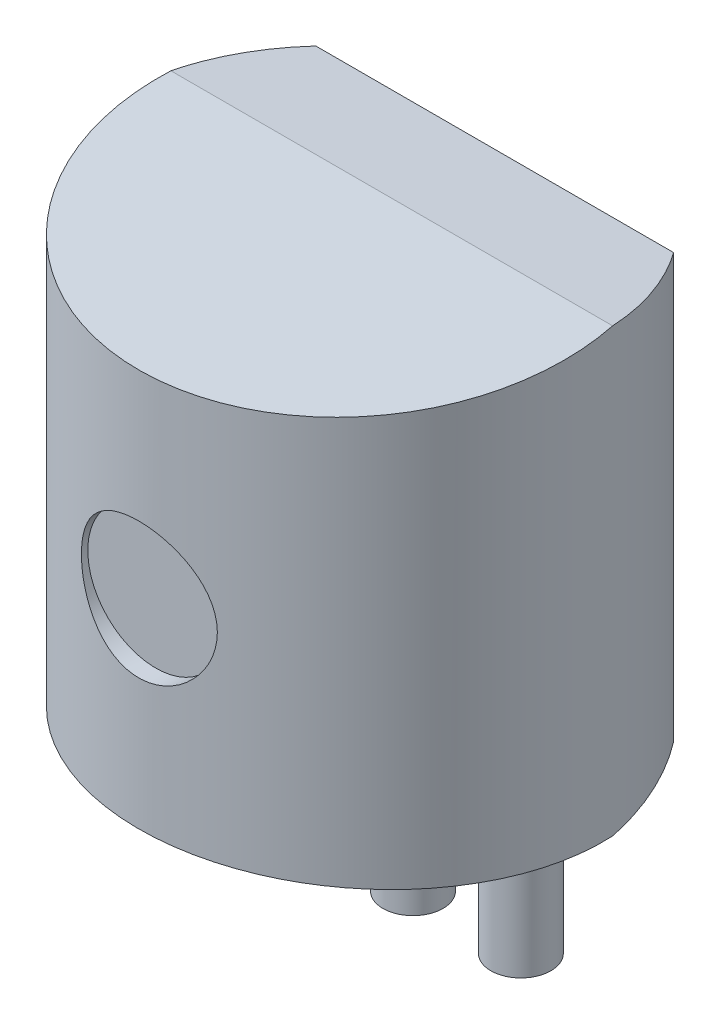
from build123d import *

# Parameters (mm, degrees)
BOSS_EXTRUDE1_DEPTH        = 2.6
SKETCH5_W                  = 11.826356456
SKETCH5_H                  = 5.621169426
CUT_EXTRUDE2_DEPTH         = 1.105635064
SKETCH6_W                  = 11.690711404
SKETCH6_H                  = 7.254613366
CUT_EXTRUDE3_DEPTH         = 5.2
BOSS_EXTRUDE2_START        = -0.052804
SKETCH7_R                  = 0.353553391
BOSS_EXTRUDE2_DEPTH        = 12.752804
SKETCH8_R                  = 0.8
CUT_EXTRUDE4_DEPTH         = 0.2
CROQUIS1_W                 = 6.923561314
CROQUIS1_H                 = 11.497610845
CORTAR_EXTRUIR1_DEPTH      = 5
CORTAR_EXTRUIR1_DEPTH_BACK = 5


with BuildPart() as part:
    # Sketch2 → Boss-Extrude1 (new body, symmetric)
    with BuildSketch(Plane(origin=(0, 0, 0), x_dir=(1, 0, 0), z_dir=(0, 1, 0))):
        with BuildLine():
            Line((-2.105447518, 1.212026432), (2.105447518, 1.212026432))
            ThreePointArc((2.105447518, 1.212026432), (0, -2.977973568), (-2.105447518, 1.212026432))
        make_face()
    extrude(amount=BOSS_EXTRUDE1_DEPTH, both=True)

    # Sketch5 → Cut-Extrude2 (cut, through all)
    with BuildSketch(Plane(origin=(0, 2.580250079, -0.225742631), x_dir=(1, 0, 0), z_dir=(0, 0.996194698, -0.087155743))):
        with Locations((0.924694538, -0.744658901)):
            Rectangle(SKETCH5_W, SKETCH5_H)
    cut_extrude2 = extrude(amount=CUT_EXTRUDE2_DEPTH, mode=Mode.SUBTRACT)

    # Sketch6 → Cut-Extrude3 (cut)
    with BuildSketch(Plane(origin=(0, 2.580250079, 0.225742631), x_dir=(1, 0, 0), z_dir=(0, 0.996194698, 0.087155743))):
        with Locations((0.257342704, -2.465539164)):
            Rectangle(SKETCH6_W, SKETCH6_H)
    cut_extrude3 = extrude(amount=CUT_EXTRUDE3_DEPTH, mode=Mode.SUBTRACT)

    # Mirror1: Cut-Extrude2, Cut-Extrude3 across plane
    add(cut_extrude2.mirror(Plane.ZX), mode=Mode.SUBTRACT)
    add(cut_extrude3.mirror(Plane.ZX), mode=Mode.SUBTRACT)

    # Sketch7 → Boss-Extrude2 (add)
    with BuildSketch(Plane(origin=(0, -2.6, 0), x_dir=(-1, 0, 0), z_dir=(0, -1, 0)).offset(BOSS_EXTRUDE2_START)):
        with Locations((-1.27, 0.25)):
            Circle(SKETCH7_R)
        with Locations((0, 0.25)):
            Circle(SKETCH7_R)
        with Locations((1.27, 0.25)):
            Circle(SKETCH7_R)
    extrude(amount=BOSS_EXTRUDE2_DEPTH)

    # Sketch8 → Cut-Extrude4 (cut)
    with BuildSketch(Plane.XY.offset(2.977973568)):
        Circle(SKETCH8_R)
    extrude(amount=-CUT_EXTRUDE4_DEPTH, mode=Mode.SUBTRACT)

    # Croquis1 → Cortar-Extruir1 (cut, two sides)
    with BuildSketch(Plane(origin=(0, 0, 0), x_dir=(0, 0, -1), z_dir=(1, 0, 0))) as cortar_extruir1_sk:
        with Locations((0.104321276, -10.336671587)):
            Rectangle(CROQUIS1_W, CROQUIS1_H)
    extrude(amount=CORTAR_EXTRUIR1_DEPTH, mode=Mode.SUBTRACT)
    extrude(cortar_extruir1_sk.sketch, amount=-CORTAR_EXTRUIR1_DEPTH_BACK, mode=Mode.SUBTRACT)


solid = part.part
